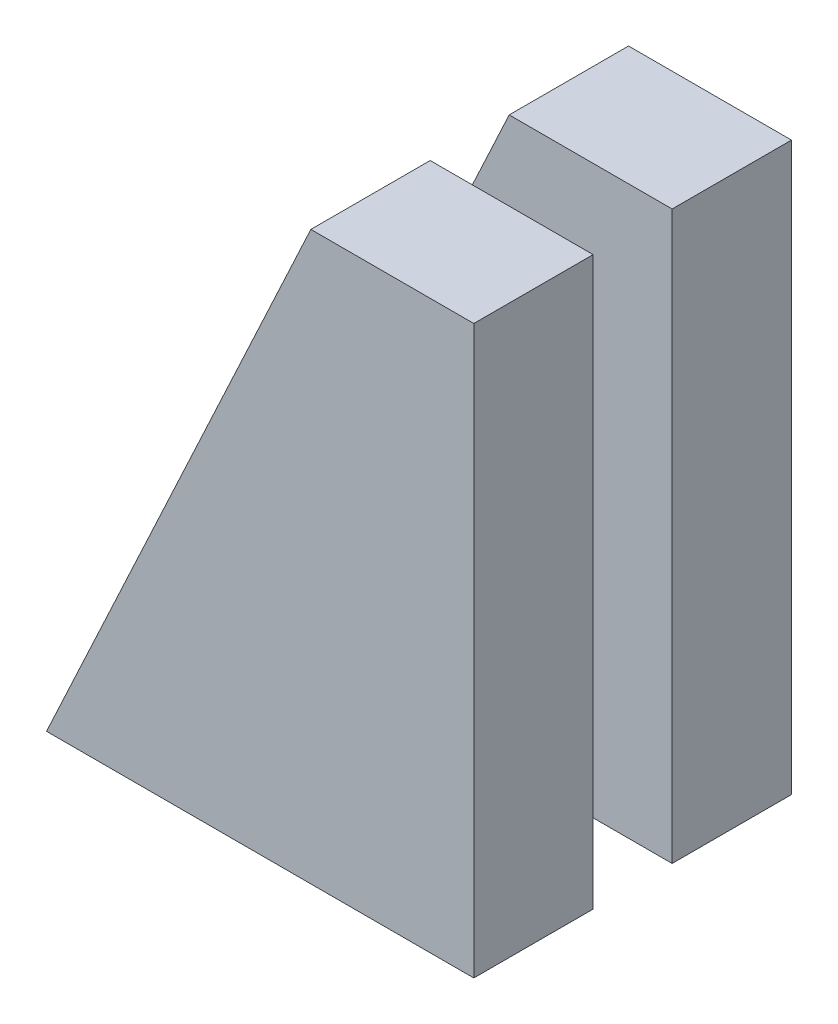
from build123d import *

# Parameters (mm, degrees)
EXTRUDE_1_DEPTH        = 140
PATTERN_LINEAR_1_COUNT = 2
PATTERN_LINEAR_1_PITCH = 232.7


with BuildPart() as part:
    # 草图1 → 凸台-拉伸1 (new body)
    with BuildSketch(Plane.XY):
        Polygon((-150, 635), (-446.105362928, 0), (0, 0), (0, 635), align=None)
        Polygon((-150, 635), (0, 635), (0, 665), (-191.179666203, 665), (-501.274258877, 0), (-446.105362928, 0), align=None)
    extrude(amount=EXTRUDE_1_DEPTH)


with BuildPart() as pattern_linear_1_1:
    # 阵列(线性)1: pattern copy
    add(part.part.moved(Location(Vector(0, 0, 1) * (1 * PATTERN_LINEAR_1_PITCH))))


solid = Compound([part.part, pattern_linear_1_1.part])
